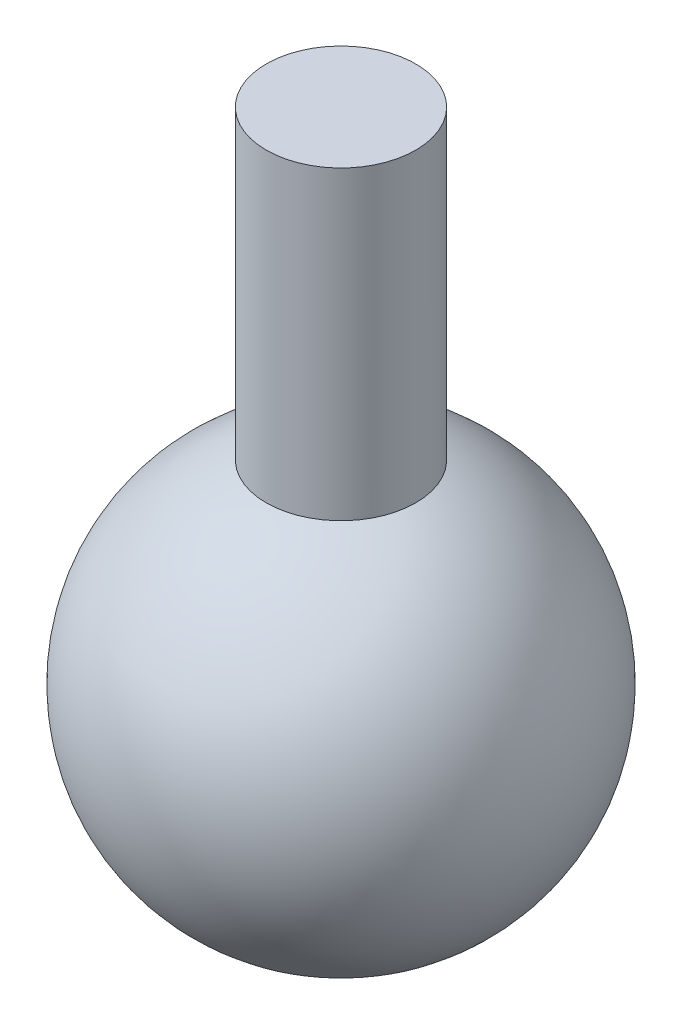
from build123d import *


with BuildPart() as part:
    # Sketch1 → Revolve1 (revolve)
    with BuildSketch(Plane.XY):
        with BuildLine():
            Line((0, 28.880652216), (0, -12.027079949))
            ThreePointArc((0, -12.027079949), (11.82479673, -2.196550567), (4.319213653, 11.224751469))
            Line((4.319213653, 11.224751469), (4.319213653, 28.880652216))
            Line((4.319213653, 28.880652216), (0, 28.880652216))
        make_face()
    revolve(axis=Axis((0, 28.880652216, 0), (0, -1, 0)))


solid = part.part
